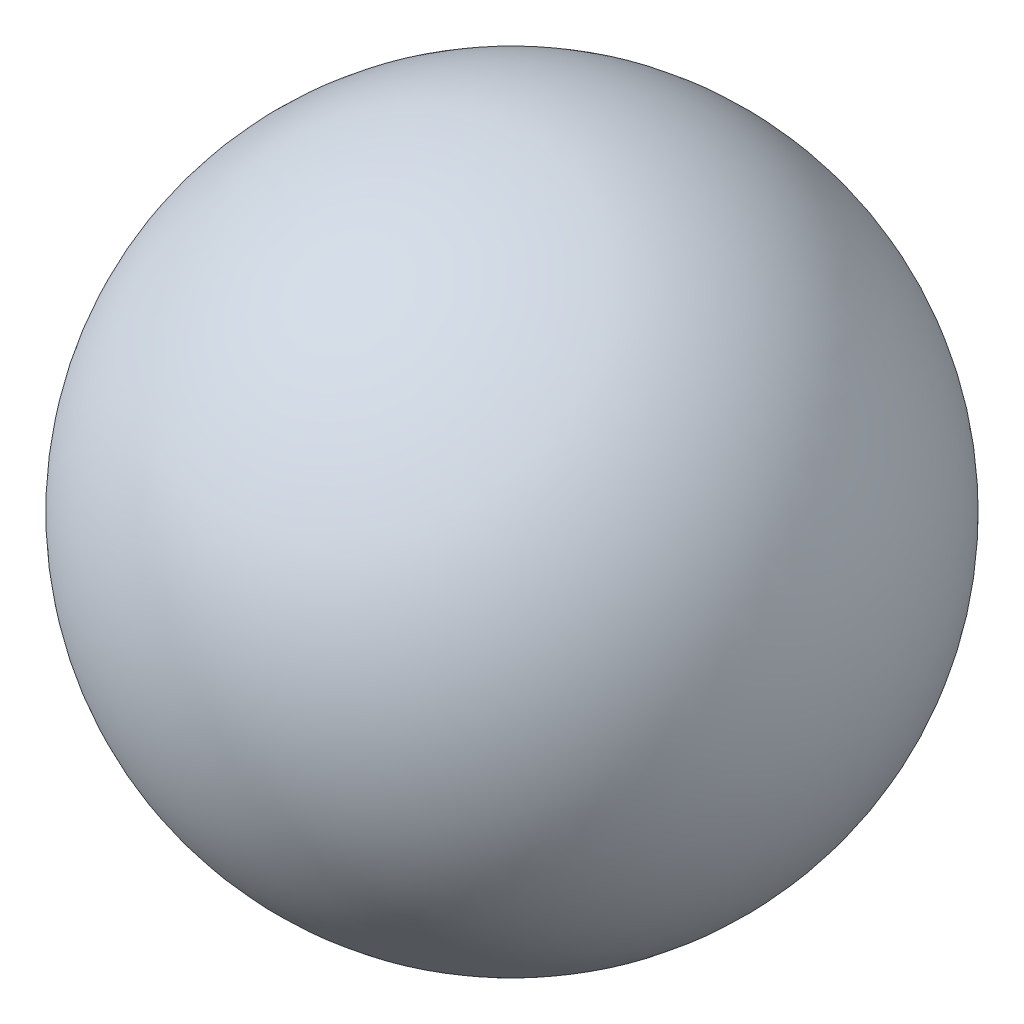
from build123d import *


with BuildPart() as part:
    # Skizze1 → Rotation1 (revolve)
    with BuildSketch(Plane.XY):
        with BuildLine():
            Line((0, 0), (0, 25))
            ThreePointArc((0, 25), (-25, 0), (0, -25))
            Line((0, -25), (0, 0))
        make_face()
    revolve(axis=Axis((0, 0, 0), (0, 1, 0)))


solid = part.part
